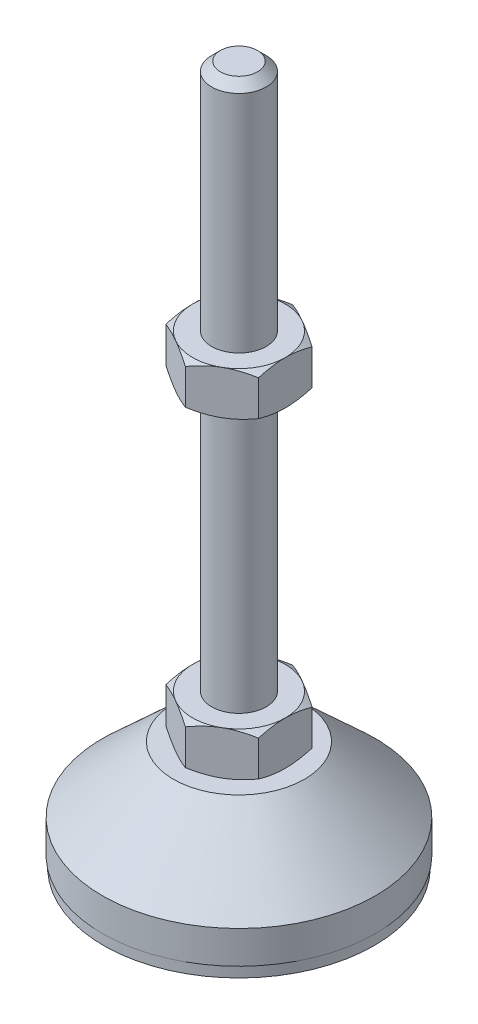
from build123d import *

# Parameters (mm, degrees)
EXTRUDE_1_DEPTH = 8
EXTRUDE_2_DEPTH = 8


with BuildPart() as part:
    # Эскиз1 → Повернуть1 (revolve)
    with BuildSketch(Plane.XY, mode=Mode.PRIVATE) as revolve_1_sk:
        Polygon((0, 0), (-24.8, 0), (-24.8, 2), (-25, 2), (-25, 8), (-12, 20), (-5, 20), (-5, 28), (-5, 126.4), (-3.4, 128), (0, 128), align=None)
    revolve(revolve_1_sk.sketch.rotate(Axis((0, 0, 0), (0, 1, 0)), 180), axis=Axis((0, 0, 0), (0, 1, 0)))  # turned: the seam where the file's is

    # Эскиз2 → Бобышка-Вытянуть1 (add)
    with BuildSketch(Plane(origin=(0, 20, 0), x_dir=(1, 0, 0), z_dir=(0, 1, 0))):
        Polygon((0, 9.814954576), (-8.5, 4.907477288), (-8.5, -4.907477288), (0, -9.814954576), (8.5, -4.907477288), (8.5, 4.907477288), align=None)
    extrude(amount=EXTRUDE_1_DEPTH)

    # Эскиз3 → Бобышка-Вытянуть2 (add)
    with BuildSketch(Plane(origin=(0, 77.2, 0), x_dir=(1, 0, 0), z_dir=(0, 1, 0))):
        Polygon((8.5, 4.907477288), (0, 9.814954576), (-8.5, 4.907477288), (-8.5, -4.907477288), (0, -9.814954576), (8.5, -4.907477288), align=None)
    extrude(amount=EXTRUDE_2_DEPTH)

    # Эскиз4 → Вырез-Повернуть2 (revolve, cut)
    with BuildSketch(Plane.XY, mode=Mode.PRIVATE) as cut_revolve_2_sk:
        Polygon((-15.42820323, 85.2), (-8.5, 85.2), (-15.42820323, 81.2), align=None)
        Polygon((-15.42820323, 77.2), (-15.42820323, 81.2), (-8.5, 77.2), align=None)
        Polygon((-15.42820323, 28), (-15.42820323, 24), (-8.5, 28), align=None)
        Polygon((-15.42820323, 24), (-15.42820323, 20), (-8.5, 20), align=None)
    revolve(cut_revolve_2_sk.sketch.rotate(Axis((0, 128, 0), (0, -1, 0)), 180), axis=Axis((0, 128, 0), (0, -1, 0)), mode=Mode.SUBTRACT)  # turned: the seam where the file's is


solid = part.part
